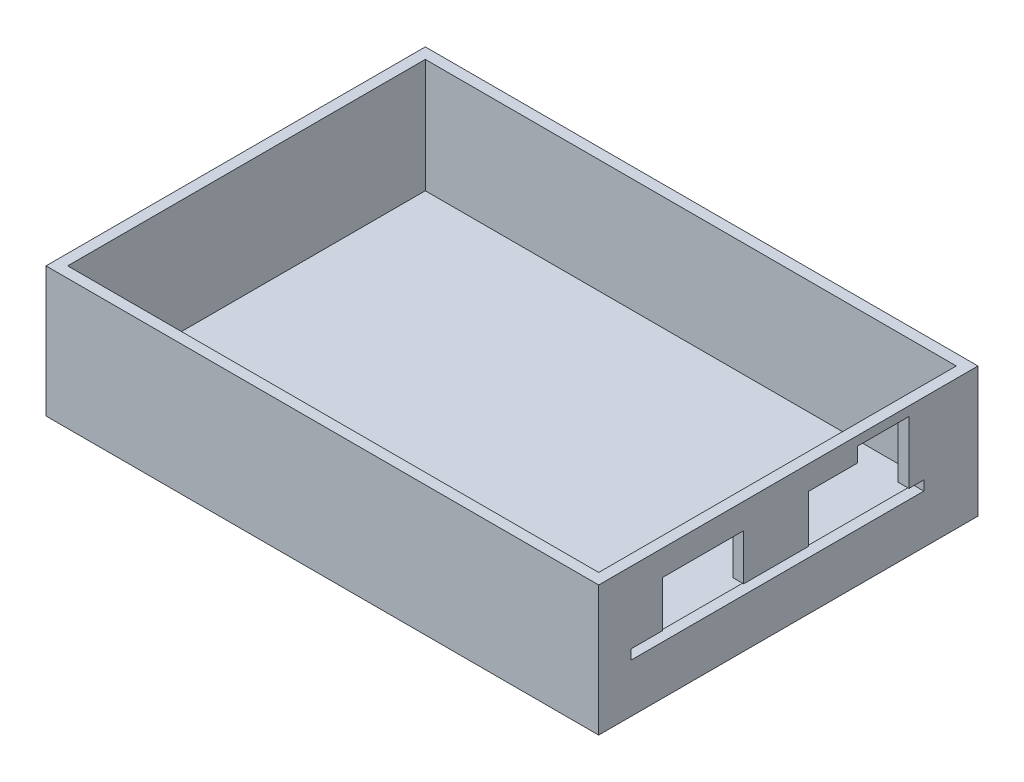
from build123d import *

# Parameters (mm, degrees)
CROQUIS1_W              = 102
CROQUIS1_H              = 70
SALIENTE_EXTRUIR1_DEPTH = 24
CROQUIS2_W              = 98
CROQUIS2_H              = 66
CORTAR_EXTRUIR1_DEPTH   = 21
CORTAR_EXTRUIR2_DEPTH   = 2


with BuildPart() as part:
    # Croquis1 → Saliente-Extruir1 (new body)
    with BuildSketch(Plane(origin=(0, 0, 0), x_dir=(1, 0, 0), z_dir=(0, 1, 0))):
        with Locations((51, 35)):
            Rectangle(CROQUIS1_W, CROQUIS1_H)
    extrude(amount=SALIENTE_EXTRUIR1_DEPTH)

    # Croquis2 → Cortar-Extruir1 (cut)
    with BuildSketch(Plane(origin=(0, 24, 0), x_dir=(1, 0, 0), z_dir=(0, 1, 0))):
        with Locations((51, 35)):
            Rectangle(CROQUIS2_W, CROQUIS2_H)
    extrude(amount=-CORTAR_EXTRUIR1_DEPTH, mode=Mode.SUBTRACT)

    # Croquis3 → Cortar-Extruir2 (cut)
    with BuildSketch(Plane(origin=(102, 0, 0), x_dir=(0, 0, -1), z_dir=(1, 0, 0))):
        Polygon((6, 9), (60, 9), (60, 10.8), (57.25, 10.8), (57.25, 22.3), (47.75, 22.3), (47.75, 19.6), (38.75, 19.6), (38.75, 10.8), (26.75, 10.8), (26.75, 19.3), (11.75, 19.3), (11.75, 10.8), (6, 10.8), align=None)
    extrude(amount=-CORTAR_EXTRUIR2_DEPTH, mode=Mode.SUBTRACT)


solid = part.part
